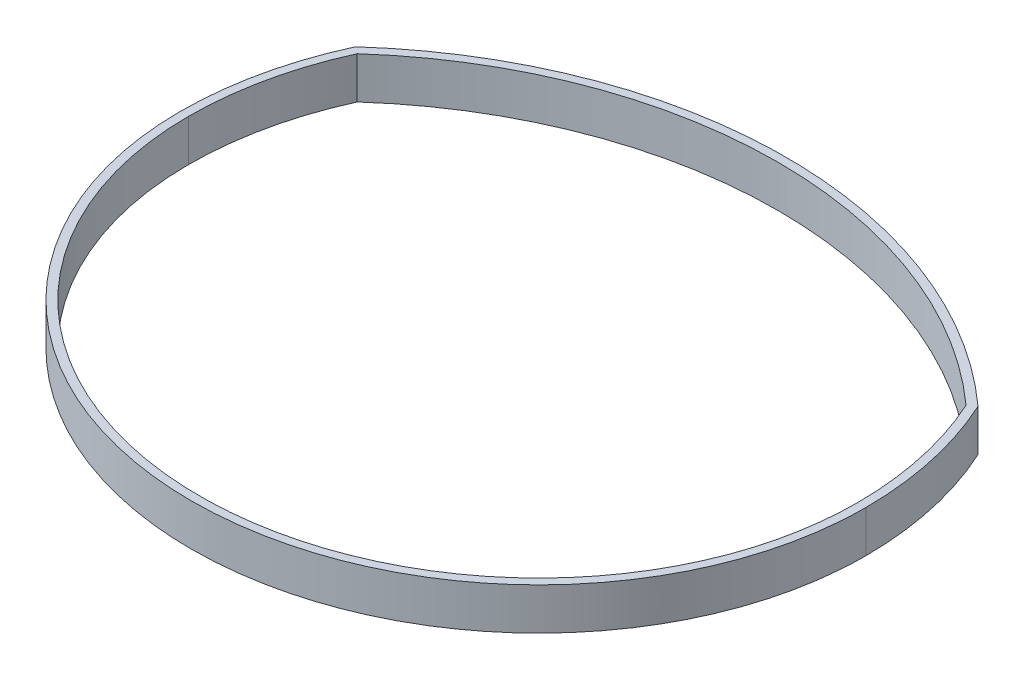
from build123d import *

# Parameters (mm, degrees)
BOSS_EXTRUDE1_DEPTH = 12.7


with BuildPart() as part:
    # Sketch1 → Boss-Extrude1 (new body)
    with BuildSketch(Plane(origin=(0, 0, 0), x_dir=(1, 0, 0), z_dir=(0, 1, 0))):
        with BuildLine():
            ThreePointArc((94.540146528, 43.672649272), (0, 80.034125107), (-94.540146528, 43.672649272))
            ThreePointArc((-94.540146528, 43.672649272), (-101.711726117, 22.357646796), (-104.14, 0))
            add(Edge.make_bspline(
                [(-104.14, 0), (-104.14, -6.586216427), (-102.793867124, -19.787350988), (-94.835263179, -45.144543739), (-75.521505284, -73.074611042), (-40.855790622, -95.438590327), (0, -103.286907831), (40.855790622, -95.438590327), (75.521505284, -73.074611042), (94.835263179, -45.144543739), (102.793867124, -19.787350988), (104.14, -6.586216427), (104.14, 0)],
                knots=[0, 0, 0, 0, 0.196349541, 0.392699082, 0.785398163, 1.178097245, 1.570796327, 1.963495408, 2.35619449, 2.748893572, 2.945243113, 3.141592654, 3.141592654, 3.141592654, 3.141592654], degree=3))
            ThreePointArc((104.14, 0), (101.711726117, 22.357646796), (94.540146528, 43.672649272))
        make_face()
        with BuildLine():
            ThreePointArc((-92.45080744, 42.135593074), (-99.28635867, 21.558733312), (-101.6, 0))
            add(Edge.make_bspline(
                [(-101.6, 0), (-101.6, -98.130801996), (0, -98.130801996), (101.6, -98.130801996), (101.6, 0)],
                knots=[0, 0, 0, 1.570796327, 1.570796327, 3.141592654, 3.141592654, 3.141592654], degree=2, weights=[1, 0.707106781, 1, 0.707106781, 1]))
            ThreePointArc((101.6, 0), (99.28635867, 21.558733312), (92.45080744, 42.135593074))
            ThreePointArc((92.45080744, 42.135593074), (0, 77.494125107), (-92.45080744, 42.135593074))
        make_face(mode=Mode.SUBTRACT)
    extrude(amount=BOSS_EXTRUDE1_DEPTH)


solid = part.part
